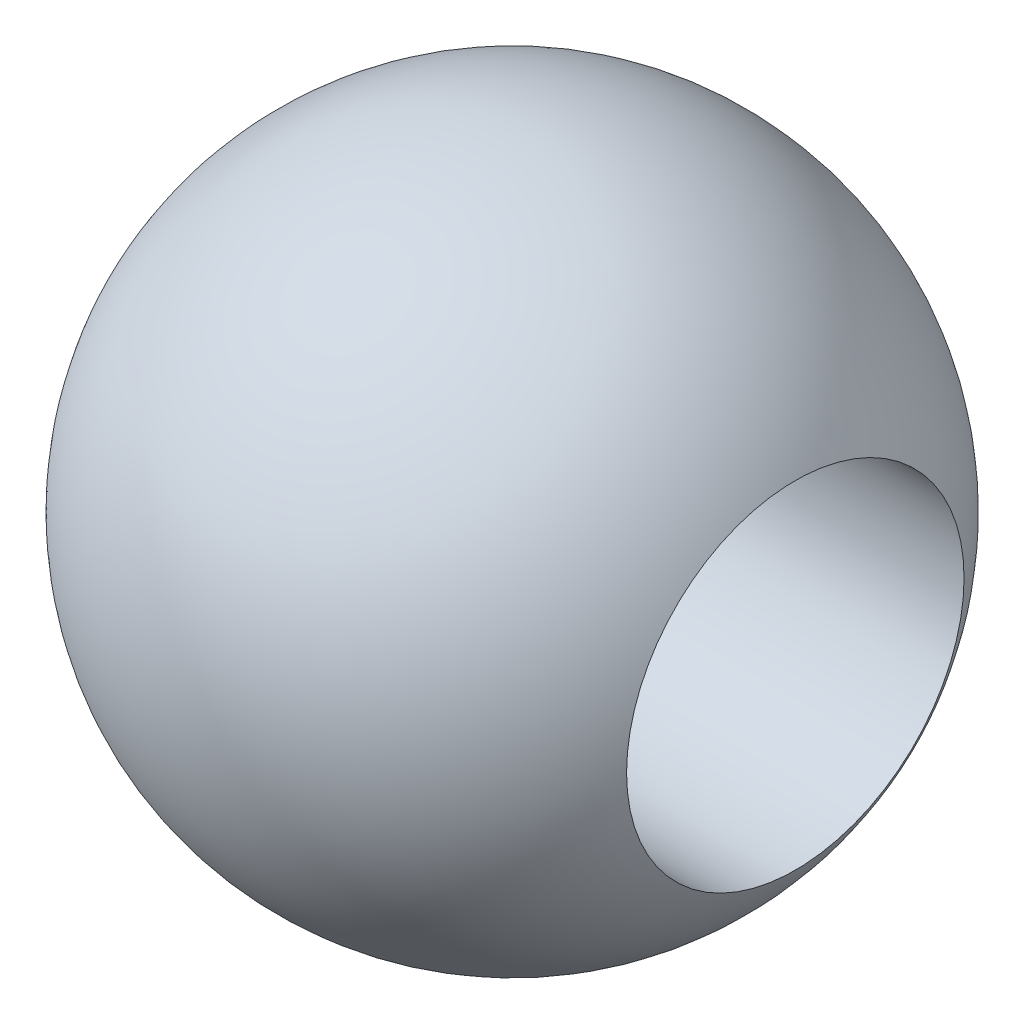
from build123d import *

# Parameters (mm, degrees)
SKETCH2_R               = 1.5
CUT_EXTRUDE1_DEPTH      = 3.93
CUT_EXTRUDE1_DEPTH_BACK = 3.93


with BuildPart() as part:
    # Sketch1 → Revolve1 (revolve)
    with BuildSketch(Plane.XY):
        with BuildLine():
            Line((0, 2.93), (0, -2.93))
            ThreePointArc((0, -2.93), (2.93, 0), (0, 2.93))
        make_face()
    revolve(axis=Axis((0, 11.641323178, 0), (0, -1, 0)))

    # Sketch2 → Cut-Extrude1 (cut, two sides)
    with BuildSketch(Plane(origin=(0, 0, 0), x_dir=(0, 0, -1), z_dir=(1, 0, 0))) as cut_extrude1_sk:
        Circle(SKETCH2_R)
    extrude(amount=CUT_EXTRUDE1_DEPTH, mode=Mode.SUBTRACT)
    extrude(cut_extrude1_sk.sketch, amount=-CUT_EXTRUDE1_DEPTH_BACK, mode=Mode.SUBTRACT)


solid = part.part
